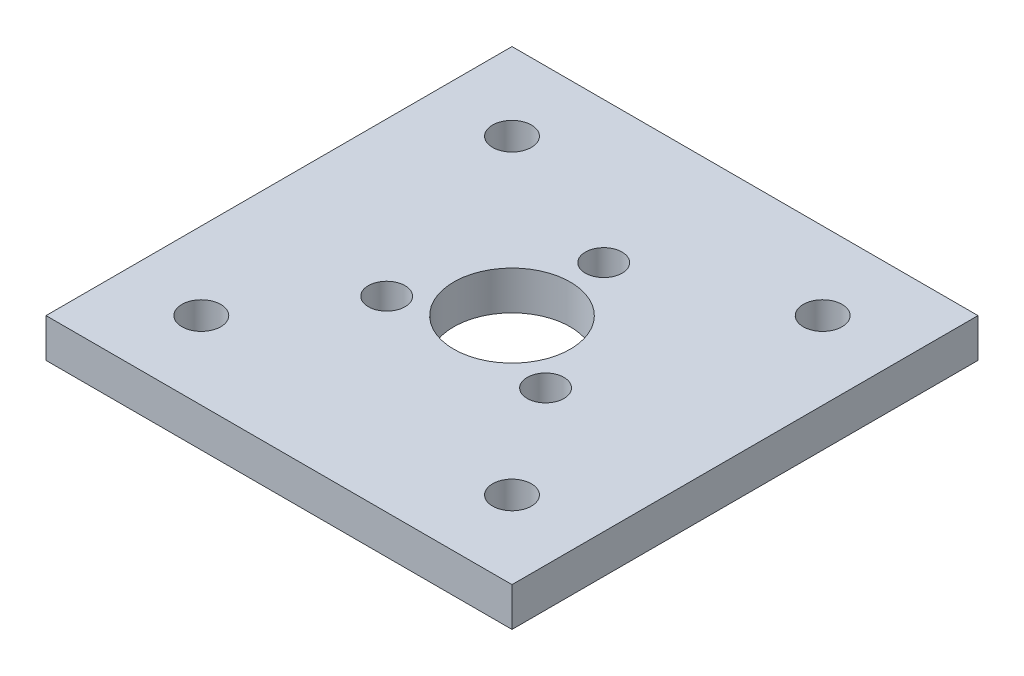
from build123d import *

# Parameters (mm, degrees)
SKETCH1_W           = 38.1
SKETCH1_H           = 38.1
BOSS_EXTRUDE1_DEPTH = 3.175
SKETCH2_R           = 1.5
SKETCH2_R_2         = 4.7625
CUT_EXTRUDE1_DEPTH  = 4.175
SKETCH3_R           = 1.5875
CUT_EXTRUDE2_DEPTH  = 4.175


with BuildPart() as part:
    # Sketch1 → Boss-Extrude1 (new body)
    with BuildSketch(Plane(origin=(0, 0, 0), x_dir=(1, 0, 0), z_dir=(0, 1, 0))):
        Rectangle(SKETCH1_W, SKETCH1_H)
    extrude(amount=BOSS_EXTRUDE1_DEPTH)

    # Sketch2 → Cut-Extrude1 (cut, through all)
    with BuildSketch(Plane(origin=(0, 3.175, 0), x_dir=(1, 0, 0), z_dir=(0, 1, 0))):
        with Locations((0, 7.5)):
            Circle(SKETCH2_R)
        with Locations((6.495190528, -3.75)):
            Circle(SKETCH2_R)
        with Locations((-6.495190528, -3.75)):
            Circle(SKETCH2_R)
        Circle(SKETCH2_R_2)
    extrude(amount=-CUT_EXTRUDE1_DEPTH, mode=Mode.SUBTRACT)

    # Sketch3 → Cut-Extrude2 (cut, through all)
    with BuildSketch(Plane(origin=(0, 3.175, 0), x_dir=(1, 0, 0), z_dir=(0, 1, 0))):
        with Locations((-12.7, 12.7)):
            Circle(SKETCH3_R)
        with Locations((-12.7, -12.7)):
            Circle(SKETCH3_R)
        with Locations((12.7, -12.7)):
            Circle(SKETCH3_R)
        with Locations((12.7, 12.7)):
            Circle(SKETCH3_R)
    extrude(amount=-CUT_EXTRUDE2_DEPTH, mode=Mode.SUBTRACT)


solid = part.part
